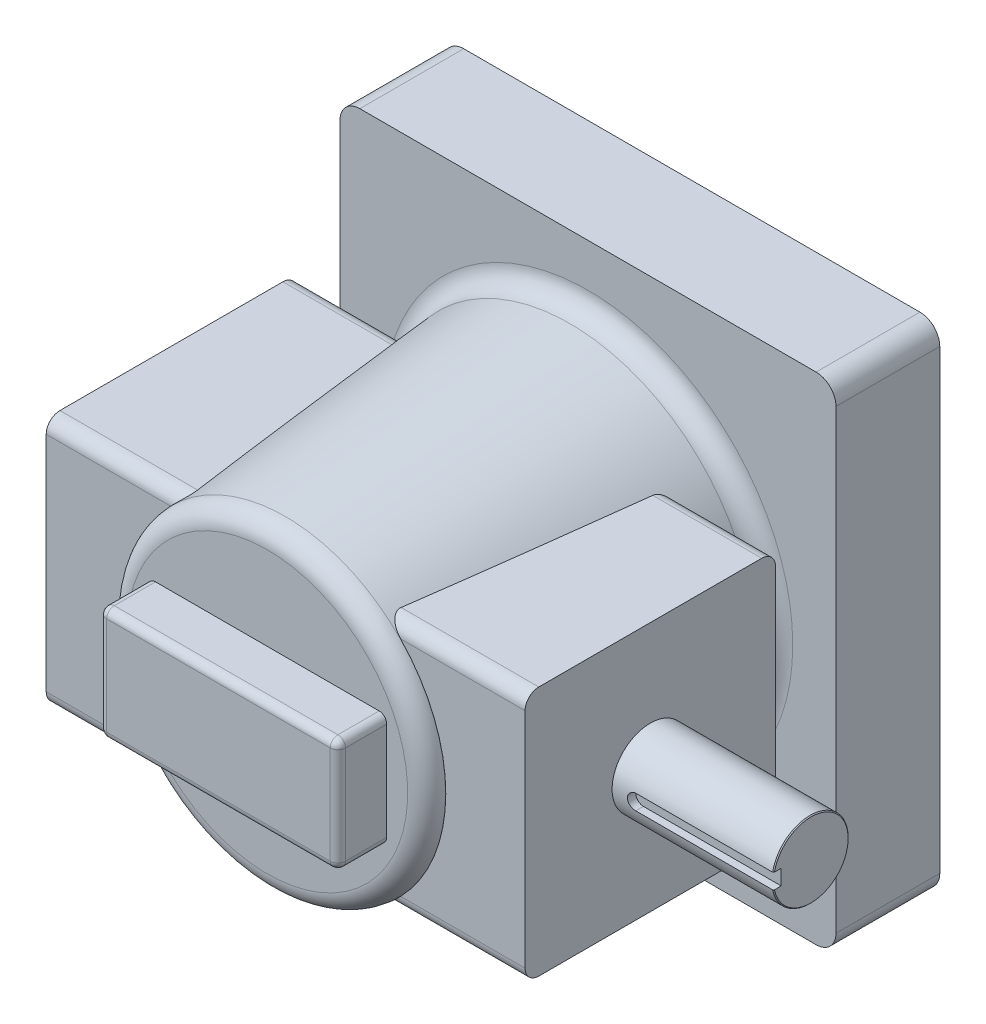
from build123d import *

# Parameters (mm, degrees)
SKETCH1_W           = 206.248
SKETCH1_H           = 206.248
C_DIM_DEPTH         = 43.18
SHAFT_START         = 12.7
SKETCH_A_R          = 15.875
SHAFT_DEPTH         = 153.67
SKETCH3_W           = 104.14
SKETCH3_H           = 104.14
BOSS_EXTRUDE3_DEPTH = 99.568
FILLET1_R           = 5.715
FILLET4_R           = 5.715
SKETCH4_R           = 77.597
BOSS_EXTRUDE4_DEPTH = 133.35
BOSS_EXTRUDE4_TAPER = 5
FILLET2_R           = 8.255
SKETCH5_W           = 99.328405226
SKETCH5_H           = 47.124202614
BOSS_EXTRUDE5_DEPTH = 20.32
CHAMFER1_SIZE       = 0.381
FILLET3_R           = 3.175
CUT_EXTRUDE_START   = 12.3698
CUT_EXTRUDE_B_DEPTH = 68.6402


with BuildPart() as part:
    # Sketch1 → C dim (new body)
    with BuildSketch(Plane.XY):
        Rectangle(SKETCH1_W, SKETCH1_H)
    extrude(amount=C_DIM_DEPTH)



with BuildPart() as body_2:
    # Sketch A → Shaft (new body)
    with BuildSketch(Plane(origin=(0, 0, 0), x_dir=(0, 0, -1), z_dir=(1, 0, 0)).offset(SHAFT_START)):
        with Locations((-116.84, 0)):
            Circle(SKETCH_A_R)
    extrude(amount=SHAFT_DEPTH)

    # Chamfer1
    chamfer1_edges = [body_2.edges().sort_by_distance(p)[0] for p in [
        (166.37, 0, 132.715),
    ]]
    chamfer(chamfer1_edges, length=CHAMFER1_SIZE)

    # Sketch6 → Cut-Extrude B (cut, through all)
    with BuildSketch(Plane.XY.offset(116.84).offset(CUT_EXTRUDE_START)):
        with BuildLine():
            Line((166.37, -3.175), (109.093, -3.175))
            ThreePointArc((109.093, -3.175), (105.918, 0), (109.093, 3.175))
            Line((109.093, 3.175), (166.37, 3.175))
            ThreePointArc((166.37, 3.175), (169.545, 0), (166.37, -3.175))
        make_face()
    extrude(amount=CUT_EXTRUDE_B_DEPTH, mode=Mode.SUBTRACT)


with BuildPart() as body_3:
    # Sketch3 → Boss-Extrude3 (new body)
    with BuildSketch(Plane(origin=(0, 0, 0), x_dir=(0, 0, -1), z_dir=(1, 0, 0))):
        with Locations((-116.84, 0)):
            Rectangle(SKETCH3_W, SKETCH3_H)
    extrude(amount=BOSS_EXTRUDE3_DEPTH)


with BuildPart() as body_4:
    # Mirror2: mirrored copy
    add(body_3.part.mirror(Plane(origin=(0, 0, 0), x_dir=(0, 0, 1), z_dir=(1, 0, 0))))

    # Fillet4
    fillet4_edges = [body_4.edges().sort_by_distance(p)[0] for p in [
        (-49.784, 52.07, 64.77),
        (-49.784, 52.07, 168.91),
        (-49.784, -52.07, 168.91),
        (-49.784, -52.07, 64.77),
    ]]
    fillet(fillet4_edges, radius=FILLET4_R)


with BuildPart() as body_3_1:
    add(body_3.part)

    # Fillet1
    fillet1_edges = [body_3_1.edges().sort_by_distance(p)[0] for p in [
        (49.784, 52.07, 64.77),
        (49.784, 52.07, 168.91),
        (49.784, -52.07, 168.91),
        (49.784, -52.07, 64.77),
    ]]
    fillet(fillet1_edges, radius=FILLET1_R)


with BuildPart() as part_1:
    add(part.part)

    add(body_3_1.part)  # Boss-Extrude4 merges body 3

    add(body_4.part)  # Boss-Extrude4 merges body 4
    # Sketch4 → Boss-Extrude4 (add)
    with BuildSketch(Plane.XY.offset(43.18)):
        Circle(SKETCH4_R)
    extrude(amount=BOSS_EXTRUDE4_DEPTH, taper=BOSS_EXTRUDE4_TAPER)

    # Fillet2
    fillet2_edges = [part_1.edges().sort_by_distance(p)[0] for p in [
        (-65.930386719, 0, 176.53),
        (-77.597, 0, 43.18),
        (-103.124, 103.124, 21.59),
        (103.124, 103.124, 21.59),
        (103.124, -103.124, 21.59),
        (-103.124, -103.124, 21.59),
    ]]
    fillet(fillet2_edges, radius=FILLET2_R)

    # Sketch5 → Boss-Extrude5 (add)
    with BuildSketch(Plane.XY.offset(176.53)):
        Rectangle(SKETCH5_W, SKETCH5_H)
    extrude(amount=BOSS_EXTRUDE5_DEPTH)

    # Fillet3
    fillet3_edges = [part_1.edges().sort_by_distance(p)[0] for p in [
        (-49.664202613, 23.562101307, 186.69),
        (-49.664202613, -23.562101307, 186.69),
        (49.664202613, -23.562101307, 186.69),
        (49.664202613, 23.562101307, 186.69),
        (0, 23.562101307, 196.85),
        (-49.664202613, 0, 196.85),
        (0, -23.562101307, 196.85),
        (49.664202613, 0, 196.85),
    ]]
    fillet(fillet3_edges, radius=FILLET3_R)

    # Combine1: union body 2
    add(body_2.part)


solid = part_1.part
